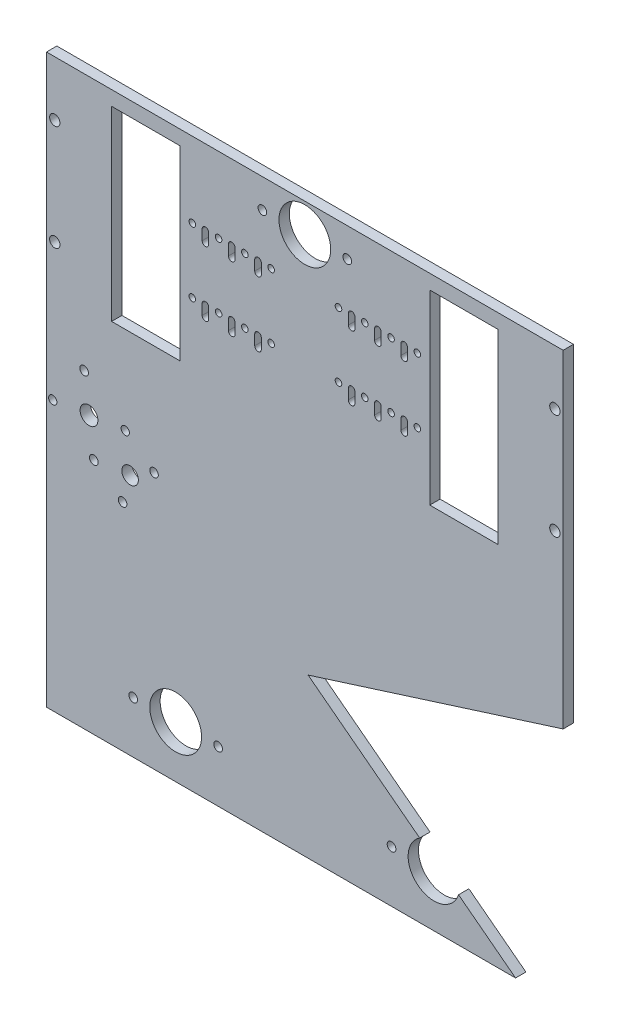
from build123d import *

# Parameters (mm, degrees)
SKETCH1_W               = 249.6
SKETCH1_H               = 340.9
SKETCH1_R               = 2.1
SKETCH1_R_2             = 2.5
SKETCH1_R_3             = 1.59
SKETCH1_R_4             = 12.5
SKETCH1_W_2             = 33
SKETCH1_H_2             = 90
BOSS_EXTRUDE1_DEPTH     = 5
CUT_EXTRUDE3_DEPTH      = 193
CUT_EXTRUDE3_DEPTH_BACK = 193
CUT_EXTRUDE6_DEPTH      = 6
SKETCH8_R               = 2
SKETCH8_R_2             = 2.1
SKETCH8_R_3             = 2.058578644
SKETCH8_R_4             = 4
SKETCH8_R_5             = 4.3
CUT_EXTRUDE7_DEPTH      = 6
SKETCH9_R               = 12.5
SKETCH9_R_2             = 2.1
CUT_EXTRUDE8_DEPTH      = 6


with BuildPart() as part:
    # Sketch1 → Boss-Extrude1 (new body)
    with BuildSketch(Plane.XY):
        with Locations((124.8, -170.45)):
            Rectangle(SKETCH1_W, SKETCH1_H)
        with Locations((104.3, -14)):
            Circle(SKETCH1_R, mode=Mode.SUBTRACT)
        with Locations((245.6, -26.5)):
            Circle(SKETCH1_R_2, mode=Mode.SUBTRACT)
        with Locations((245.6, -77.5)):
            Circle(SKETCH1_R_2, mode=Mode.SUBTRACT)
        with Locations((145.3, -14)):
            Circle(SKETCH1_R, mode=Mode.SUBTRACT)
        with Locations((179.16, -36.375)):
            Circle(SKETCH1_R_3, mode=Mode.SUBTRACT)
        with Locations((179.16, -67.625)):
            Circle(SKETCH1_R_3, mode=Mode.SUBTRACT)
        with Locations((124.8, -14)):
            Circle(SKETCH1_R_4, mode=Mode.SUBTRACT)
        with Locations((141.06, -36.375)):
            Circle(SKETCH1_R_3, mode=Mode.SUBTRACT)
        with Locations((153.76, -36.375)):
            Circle(SKETCH1_R_3, mode=Mode.SUBTRACT)
        with Locations((166.46, -36.375)):
            Circle(SKETCH1_R_3, mode=Mode.SUBTRACT)
        with Locations((141.06, -67.625)):
            Circle(SKETCH1_R_3, mode=Mode.SUBTRACT)
        with Locations((153.76, -67.625)):
            Circle(SKETCH1_R_3, mode=Mode.SUBTRACT)
        with Locations((166.46, -67.625)):
            Circle(SKETCH1_R_3, mode=Mode.SUBTRACT)
        with Locations((83.14, -67.625)):
            Circle(SKETCH1_R_3, mode=Mode.SUBTRACT)
        with Locations((95.84, -67.625)):
            Circle(SKETCH1_R_3, mode=Mode.SUBTRACT)
        with Locations((108.54, -67.625)):
            Circle(SKETCH1_R_3, mode=Mode.SUBTRACT)
        with Locations((83.14, -36.375)):
            Circle(SKETCH1_R_3, mode=Mode.SUBTRACT)
        with Locations((95.84, -36.375)):
            Circle(SKETCH1_R_3, mode=Mode.SUBTRACT)
        with Locations((108.54, -36.375)):
            Circle(SKETCH1_R_3, mode=Mode.SUBTRACT)
        with Locations((70.44, -67.625)):
            Circle(SKETCH1_R_3, mode=Mode.SUBTRACT)
        with Locations((70.44, -36.375)):
            Circle(SKETCH1_R_3, mode=Mode.SUBTRACT)
        with Locations((4, -77.5)):
            Circle(SKETCH1_R_2, mode=Mode.SUBTRACT)
        with Locations((4, -26.5)):
            Circle(SKETCH1_R_2, mode=Mode.SUBTRACT)
        with Locations((201.66, -52)):
            Rectangle(SKETCH1_W_2, SKETCH1_H_2, mode=Mode.SUBTRACT)
        with BuildLine():
            Line((145.8225, -36.375), (145.8225, -41.375))
            ThreePointArc((145.8225, -41.375), (147.41, -42.9625), (148.9975, -41.375))
            Line((148.9975, -41.375), (148.9975, -36.375))
            ThreePointArc((148.9975, -36.375), (147.41, -34.7875), (145.8225, -36.375))
        make_face(mode=Mode.SUBTRACT)
        with BuildLine():
            Line((158.52, -36.375), (158.52, -41.375))
            ThreePointArc((158.52, -41.375), (160.11, -42.965), (161.7, -41.375))
            Line((161.7, -41.375), (161.7, -36.375))
            ThreePointArc((161.7, -36.375), (160.11, -34.785), (158.52, -36.375))
        make_face(mode=Mode.SUBTRACT)
        with BuildLine():
            Line((171.22, -36.375), (171.22, -41.375))
            ThreePointArc((171.22, -41.375), (172.81, -42.965), (174.4, -41.375))
            Line((174.4, -41.375), (174.4, -36.375))
            ThreePointArc((174.4, -36.375), (172.81, -34.785), (171.22, -36.375))
        make_face(mode=Mode.SUBTRACT)
        with BuildLine():
            Line((145.8225, -67.625), (145.8225, -72.625))
            ThreePointArc((145.8225, -72.625), (147.41, -74.2125), (148.9975, -72.625))
            Line((148.9975, -72.625), (148.9975, -67.625))
            ThreePointArc((148.9975, -67.625), (147.41, -66.0375), (145.8225, -67.625))
        make_face(mode=Mode.SUBTRACT)
        with BuildLine():
            Line((158.52, -67.625), (158.52, -72.625))
            ThreePointArc((158.52, -72.625), (160.11, -74.215), (161.7, -72.625))
            Line((161.7, -72.625), (161.7, -67.625))
            ThreePointArc((161.7, -67.625), (160.11, -66.035), (158.52, -67.625))
        make_face(mode=Mode.SUBTRACT)
        with BuildLine():
            Line((171.22, -67.625), (171.22, -72.625))
            ThreePointArc((171.22, -72.625), (172.81, -74.215), (174.4, -72.625))
            Line((174.4, -72.625), (174.4, -67.625))
            ThreePointArc((174.4, -67.625), (172.81, -66.035), (171.22, -67.625))
        make_face(mode=Mode.SUBTRACT)
        with BuildLine():
            Line((103.7775, -36.375), (103.7775, -41.375))
            ThreePointArc((103.7775, -41.375), (102.19, -42.9625), (100.6025, -41.375))
            Line((100.6025, -41.375), (100.6025, -36.375))
            ThreePointArc((100.6025, -36.375), (102.19, -34.7875), (103.7775, -36.375))
        make_face(mode=Mode.SUBTRACT)
        with BuildLine():
            Line((91.08, -36.375), (91.08, -41.375))
            ThreePointArc((91.08, -41.375), (89.49, -42.965), (87.9, -41.375))
            Line((87.9, -41.375), (87.9, -36.375))
            ThreePointArc((87.9, -36.375), (89.49, -34.785), (91.08, -36.375))
        make_face(mode=Mode.SUBTRACT)
        with BuildLine():
            Line((78.38, -36.375), (78.38, -41.375))
            ThreePointArc((78.38, -41.375), (76.79, -42.965), (75.2, -41.375))
            Line((75.2, -41.375), (75.2, -36.375))
            ThreePointArc((75.2, -36.375), (76.79, -34.785), (78.38, -36.375))
        make_face(mode=Mode.SUBTRACT)
        with BuildLine():
            Line((103.7775, -67.625), (103.7775, -72.625))
            ThreePointArc((103.7775, -72.625), (102.19, -74.2125), (100.6025, -72.625))
            Line((100.6025, -72.625), (100.6025, -67.625))
            ThreePointArc((100.6025, -67.625), (102.19, -66.0375), (103.7775, -67.625))
        make_face(mode=Mode.SUBTRACT)
        with BuildLine():
            Line((91.08, -67.625), (91.08, -72.625))
            ThreePointArc((91.08, -72.625), (89.49, -74.215), (87.9, -72.625))
            Line((87.9, -72.625), (87.9, -67.625))
            ThreePointArc((87.9, -67.625), (89.49, -66.035), (91.08, -67.625))
        make_face(mode=Mode.SUBTRACT)
        with BuildLine():
            Line((78.38, -67.625), (78.38, -72.625))
            ThreePointArc((78.38, -72.625), (76.79, -74.215), (75.2, -72.625))
            Line((75.2, -72.625), (75.2, -67.625))
            ThreePointArc((75.2, -67.625), (76.79, -66.035), (78.38, -67.625))
        make_face(mode=Mode.SUBTRACT)
        with Locations((47.94, -52)):
            Rectangle(SKETCH1_W_2, SKETCH1_H_2, mode=Mode.SUBTRACT)
    extrude(amount=BOSS_EXTRUDE1_DEPTH)

    # Sketch4 → Cut-Extrude3 (cut, two sides)
    with BuildSketch(Plane.XY.offset(5)) as cut_extrude3_sk:
        with BuildLine():
            Line((249.6, -161.594545719), (249.6, -280.754609783))
            ThreePointArc((249.6, -280.754609783), (205.980407386, -221.174577751), (249.6, -161.594545719))
        make_face()
    extrude(amount=CUT_EXTRUDE3_DEPTH, mode=Mode.SUBTRACT)
    extrude(cut_extrude3_sk.sketch, amount=-CUT_EXTRUDE3_DEPTH_BACK, mode=Mode.SUBTRACT)

    # Sketch7 → Cut-Extrude6 (cut, through all)
    with BuildSketch(Plane.XY.offset(5)):
        Polygon((249.6, -158.447518206), (126.382609779, -197.494065264), (226.608591706, -274.129323659), (0, -274.129323659), (0, -340.9), (249.6, -340.9), align=None)
    extrude(amount=-CUT_EXTRUDE6_DEPTH, mode=Mode.SUBTRACT)

    # Sketch8 → Cut-Extrude7 (cut, through all)
    with BuildSketch(Plane.XY.offset(5)):
        with Locations((3.008996966, -144.071505353)):
            Circle(SKETCH8_R)
        with Locations((18.194231921, -124.211781303)):
            Circle(SKETCH8_R_2)
        with Locations((22.868721016, -159.256740308)):
            Circle(SKETCH8_R_2)
        with Locations((36.770527851, -169.886404777)):
            Circle(SKETCH8_R_3)
        with Locations((40.391200519, -156.919495761)):
            Circle(SKETCH8_R_4)
        with Locations((38.053955971, -139.397016258)):
            Circle(SKETCH8_R)
        with Locations((20.531476469, -141.734260806)):
            Circle(SKETCH8_R_5)
        with Locations((51.955762806, -150.026680727)):
            Circle(SKETCH8_R_3)
    extrude(amount=-CUT_EXTRUDE7_DEPTH, mode=Mode.SUBTRACT)

    # Sketch9 → Cut-Extrude8 (cut, through all)
    with BuildSketch(Plane.XY.offset(5)):
        with Locations((62.4, -249.129323659)):
            Circle(SKETCH9_R)
        with Locations((82.9, -249.129323659)):
            Circle(SKETCH9_R_2)
        with Locations((41.9, -249.129323659)):
            Circle(SKETCH9_R_2)
        with Locations((207.7, -249.129323659)):
            Circle(SKETCH9_R_2)
        with Locations((166.7, -249.129323659)):
            Circle(SKETCH9_R_2)
        with Locations((187.2, -249.129323659)):
            Circle(SKETCH9_R)
    extrude(amount=-CUT_EXTRUDE8_DEPTH, mode=Mode.SUBTRACT)


solid = part.part
